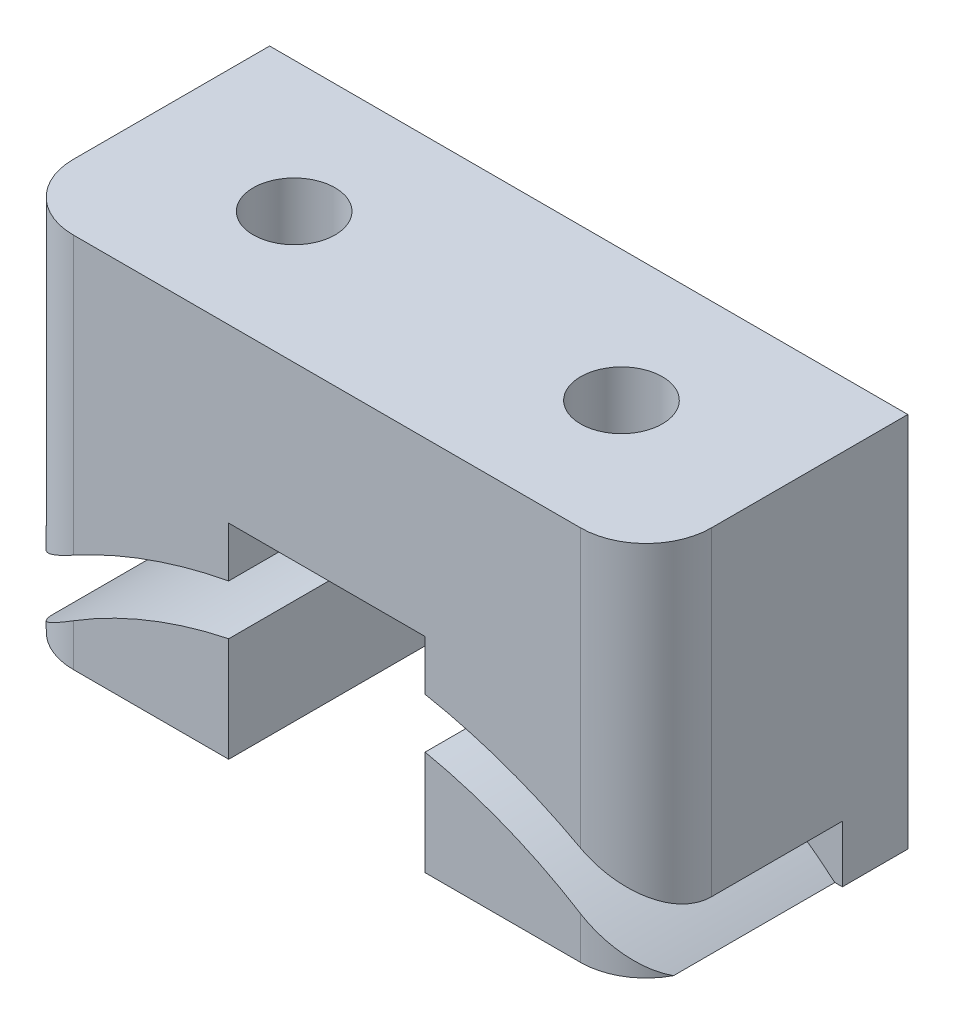
from build123d import *

# Parameters (mm, degrees)
SKETCH1_W           = 19.5
SKETCH1_H           = 11.5
BOSS_EXTRUDE1_DEPTH = 8
FILLET1_R           = 2
SKETCH2_R           = 16.2
SKETCH2_R_2         = 14.7
CUT_EXTRUDE1_DEPTH  = 6
CUT_EXTRUDE2_REACH  = 13.5
SKETCH3_R           = 1.25
SKETCH4_W           = 6
SKETCH4_H           = 12.5
CUT_EXTRUDE3_DEPTH  = 9.0000001


with BuildPart() as part:
    # Sketch1 → Boss-Extrude1 (new body)
    with BuildSketch(Plane.XY):
        with Locations((0, 0.75)):
            Rectangle(SKETCH1_W, SKETCH1_H)
    extrude(amount=BOSS_EXTRUDE1_DEPTH)

    # Fillet1
    fillet1_edges = [part.edges().sort_by_distance(p)[0] for p in [
        (-9.75, 0.75, 8),
        (9.75, 0.75, 8),
    ]]
    fillet(fillet1_edges, radius=FILLET1_R)

    # Sketch2 → Cut-Extrude1 (cut)
    with BuildSketch(Plane.XY.offset(8)):
        with Locations((0, -16.2)):
            Circle(SKETCH2_R)
        with Locations((0, -16.2)):
            Circle(SKETCH2_R_2, mode=Mode.SUBTRACT)
    extrude(amount=-CUT_EXTRUDE1_DEPTH, mode=Mode.SUBTRACT)

    # Sketch3 → Cut-Extrude2 (cut, up to next)
    with BuildSketch(Plane(origin=(0, 6.5, 0), x_dir=(1, 0, 0), z_dir=(0, 1, 0)), mode=Mode.PRIVATE) as cut_extrude2_sk1:
        with Locations((5, -4)):
            Circle(SKETCH3_R)
    cut_extrude2_tool1 = extrude(cut_extrude2_sk1.sketch, amount=-CUT_EXTRUDE2_REACH, mode=Mode.PRIVATE) & part.part
    add(cut_extrude2_tool1.solids().sort_by_distance((5, 6.5, 4))[0], mode=Mode.SUBTRACT)
    # Sketch3 → Cut-Extrude2 (cut, up to next)
    with BuildSketch(Plane(origin=(0, 6.5, 0), x_dir=(1, 0, 0), z_dir=(0, 1, 0)), mode=Mode.PRIVATE) as cut_extrude2_sk2:
        with Locations((-5, -4)):
            Circle(SKETCH3_R)
    cut_extrude2_tool2 = extrude(cut_extrude2_sk2.sketch, amount=-CUT_EXTRUDE2_REACH, mode=Mode.PRIVATE) & part.part
    add(cut_extrude2_tool2.solids().sort_by_distance((-5, 6.5, 4))[0], mode=Mode.SUBTRACT)

    # Sketch4 → Cut-Extrude3 (cut, through all)
    with BuildSketch(Plane(origin=(0, 0, 0), x_dir=(-1, 0, 0), z_dir=(0, 0, -1))):
        with Locations((0, -5)):
            Rectangle(SKETCH4_W, SKETCH4_H)
    extrude(amount=-CUT_EXTRUDE3_DEPTH, mode=Mode.SUBTRACT)


solid = part.part
